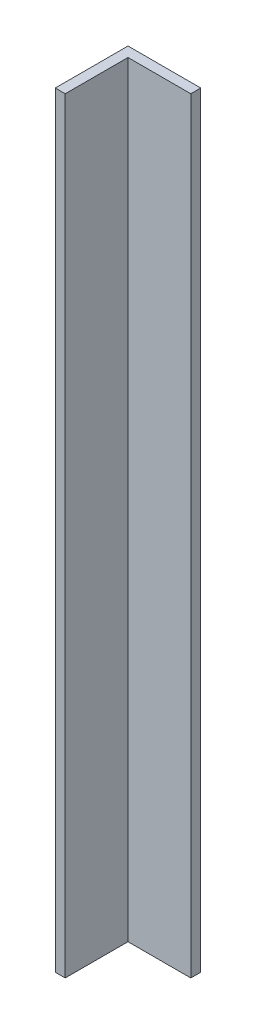
from build123d import *

# Parameters (mm, degrees)
BOSS_EXTRUDE1_DEPTH = 200


with BuildPart() as part:
    # Sketch1 → Boss-Extrude1 (new body)
    with BuildSketch(Plane(origin=(0, 0, 0), x_dir=(1, 0, 0), z_dir=(0, 1, 0))):
        Polygon((0, 0), (16.4, 0), (16.4, 2.6), (-2.6, 2.6), (-2.6, -16.4), (0, -16.4), align=None)
    extrude(amount=BOSS_EXTRUDE1_DEPTH)


solid = part.part
